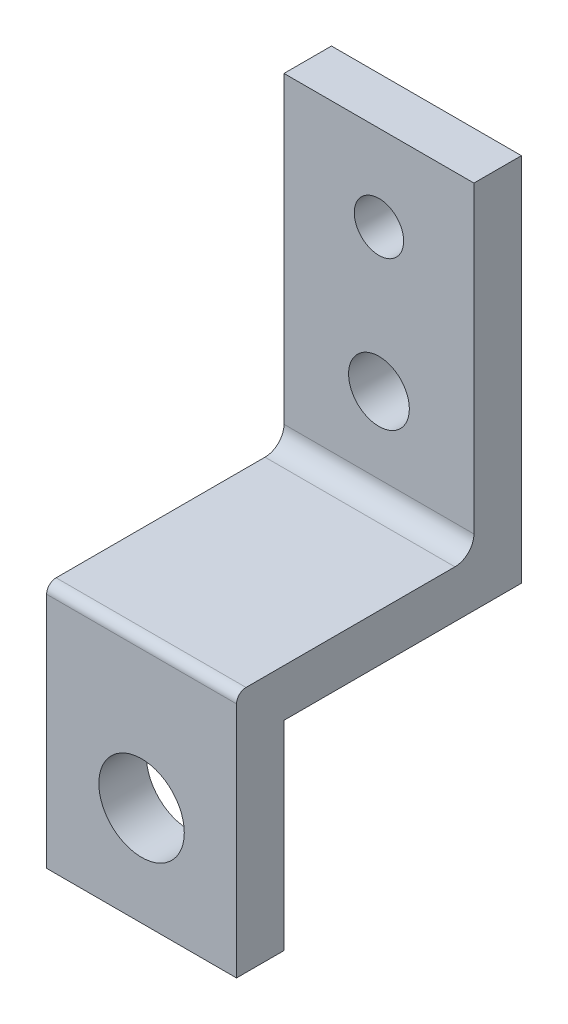
from build123d import *

# Parameters (mm, degrees)
SKETCH1_R           = 4.5
BOSS_EXTRUDE1_DEPTH = 5
SKETCH2_W           = 20
SKETCH2_H           = 39
BOSS_EXTRUDE2_DEPTH = 25
CUT_EXTRUDE1_DEPTH  = 30
SKETCH4_R           = 2.6
SKETCH4_R_2         = 3.2
CUT_EXTRUDE2_DEPTH  = 10
FILLET1_R           = 2
FILLET2_R           = 1


with BuildPart() as part:
    # Sketch1 → Boss-Extrude1 (new body)
    with BuildSketch(Plane.XY):
        Polygon((-10, 10), (-10, -10), (-10, -11), (10, -11), (10, -10), (10, 10), (10, 44), (-10, 44), align=None)
        with Locations((0, -0.5)):
            Circle(SKETCH1_R, mode=Mode.SUBTRACT)
    extrude(amount=BOSS_EXTRUDE1_DEPTH)

    # Sketch2 → Boss-Extrude2 (add)
    with BuildSketch(Plane(origin=(0, 0, 0), x_dir=(-1, 0, 0), z_dir=(0, 0, -1))):
        with Locations((0, 29.5)):
            Rectangle(SKETCH2_W, SKETCH2_H)
    extrude(amount=BOSS_EXTRUDE2_DEPTH)

    # Sketch3 → Cut-Extrude1 (cut)
    with BuildSketch(Plane(origin=(10, 0, 0), x_dir=(0, 0, -1), z_dir=(1, 0, 0))):
        Polygon((0, 15), (-5, 15), (-5, 49), (20, 49), (20, 15), align=None)
    extrude(amount=-CUT_EXTRUDE1_DEPTH, mode=Mode.SUBTRACT)

    # Sketch4 → Cut-Extrude2 (cut)
    with BuildSketch(Plane.XY.offset(-20)):
        with Locations((0, 40)):
            Circle(SKETCH4_R)
        with Locations((0, 25)):
            Circle(SKETCH4_R_2)
    extrude(amount=-CUT_EXTRUDE2_DEPTH, mode=Mode.SUBTRACT)

    # Fillet1
    fillet1_edges = [part.edges().sort_by_distance(p)[0] for p in [
        (0, 15, -20),
    ]]
    fillet(fillet1_edges, radius=FILLET1_R)

    # Fillet2
    fillet2_edges = [part.edges().sort_by_distance(p)[0] for p in [
        (0, 15, 5),
    ]]
    fillet(fillet2_edges, radius=FILLET2_R)


solid = part.part
